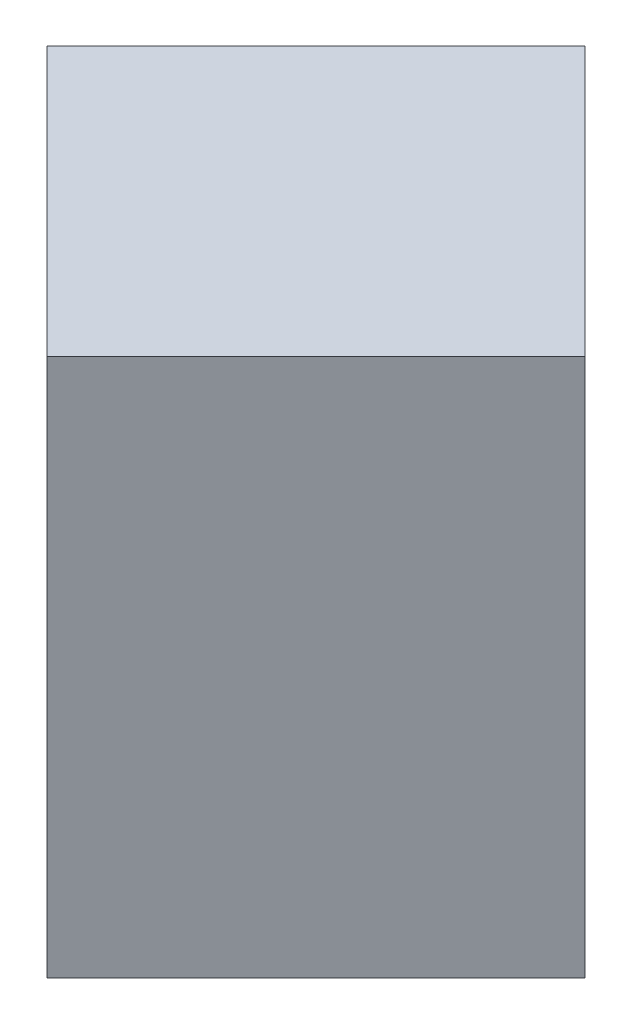
from build123d import *

# Parameters (mm, degrees)
SKETCH1_W           = 20
SKETCH1_H           = 20
BOSS_EXTRUDE1_DEPTH = 20
CUT_EXTRUDE1_DEPTH  = 20
CUT_EXTRUDE2_DEPTH  = 20
CUT_EXTRUDE3_DEPTH  = 20
CUT_EXTRUDE4_DEPTH  = 20


with BuildPart() as part:
    # Sketch1 → Boss-Extrude1 (new body)
    with BuildSketch(Plane.XY):
        with Locations((10, 10)):
            Rectangle(SKETCH1_W, SKETCH1_H)
    extrude(amount=BOSS_EXTRUDE1_DEPTH)

    # Sketch2 → Cut-Extrude1 (cut)
    with BuildSketch(Plane(origin=(0, 20, 0), x_dir=(1, 0, 0), z_dir=(0, 1, 0))):
        Polygon((20, 0), (10, 0), (20, -10), align=None)
    extrude(amount=-CUT_EXTRUDE1_DEPTH, mode=Mode.SUBTRACT)

    # Sketch3 → Cut-Extrude2 (cut)
    with BuildSketch(Plane(origin=(0, 20, 0), x_dir=(1, 0, 0), z_dir=(0, 1, 0))):
        Polygon((20, -20), (20, -10), (10, -20), align=None)
    extrude(amount=-CUT_EXTRUDE2_DEPTH, mode=Mode.SUBTRACT)

    # Sketch4 → Cut-Extrude3 (cut)
    with BuildSketch(Plane(origin=(0, 20, 0), x_dir=(1, 0, 0), z_dir=(0, 1, 0))):
        Polygon((0, 0), (10, 0), (0, -10), align=None)
    extrude(amount=-CUT_EXTRUDE3_DEPTH, mode=Mode.SUBTRACT)

    # Sketch5 → Cut-Extrude4 (cut)
    with BuildSketch(Plane(origin=(0, 20, 0), x_dir=(1, 0, 0), z_dir=(0, 1, 0))):
        Polygon((0, -20), (0, -10), (10, -20), align=None)
    extrude(amount=-CUT_EXTRUDE4_DEPTH, mode=Mode.SUBTRACT)


solid = part.part
